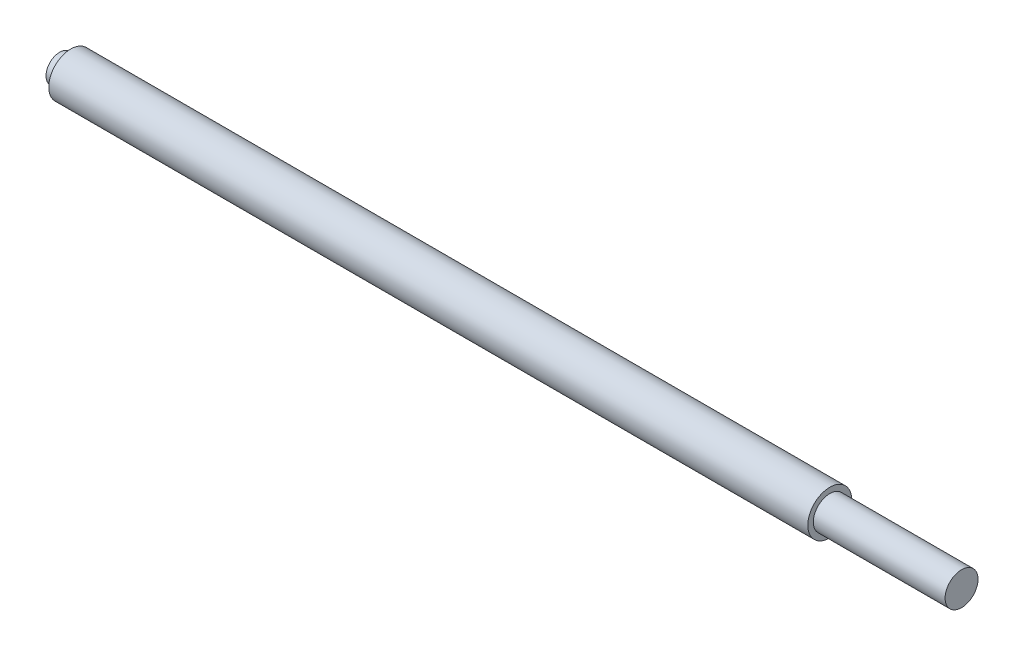
from build123d import *

# Parameters (mm, degrees)
SKETCH3_W               = 25.4
SKETCH3_H               = 3.175
CUT_EXTRUDE1_DEPTH      = 13.7
CUT_EXTRUDE1_DEPTH_BACK = 13.7


with BuildPart() as part:
    # Sketch2 → Revolve1 (revolve)
    with BuildSketch(Plane(origin=(0, 0, 0), x_dir=(1, 0, 0), z_dir=(0, 1, 0))):
        Polygon((6.35, 7.9375), (6.35, 12.7), (445.226359817, 12.7), (445.226359817, 9.525), (521.426359817, 9.525), (521.426359817, 0), (0, 0), (0, 7.9375), align=None)
    revolve(axis=Axis((0, 0, 0), (1, 0, 0)))

    # Sketch3 → Cut-Extrude1 (cut, two sides)
    with BuildSketch(Plane(origin=(0, 0, 0), x_dir=(1, 0, 0), z_dir=(0, 1, 0))) as cut_extrude1_sk:
        with Locations((209.006359817, 11.1125)):
            Rectangle(SKETCH3_W, SKETCH3_H)
    extrude(amount=CUT_EXTRUDE1_DEPTH, mode=Mode.SUBTRACT)
    extrude(cut_extrude1_sk.sketch, amount=-CUT_EXTRUDE1_DEPTH_BACK, mode=Mode.SUBTRACT)


solid = part.part
